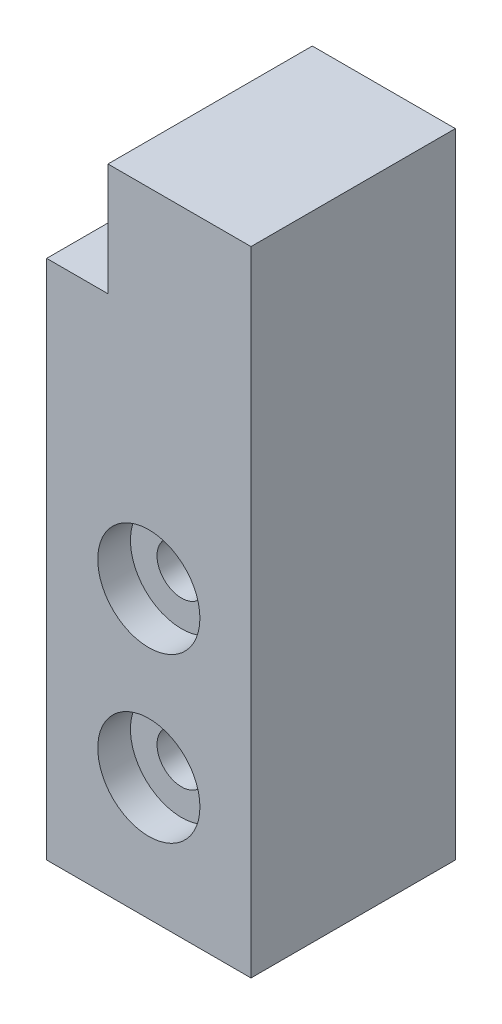
from build123d import *

# Parameters (mm, degrees)
SKETCH1_W                                = 10
SKETCH1_H                                = 31
BOSS_EXTRUDE1_DEPTH                      = 10
SKETCH2_W                                = 3
SKETCH2_H                                = 5.5
CUT_EXTRUDE1_DEPTH                       = 10
CBORE_FOR_M2_PAN_HEAD_SCREW1_D           = 2.4
CBORE_FOR_M2_PAN_HEAD_SCREW1_DEPTH       = 10
CBORE_FOR_M2_PAN_HEAD_SCREW1_CBORE_D     = 5
CBORE_FOR_M2_PAN_HEAD_SCREW1_CBORE_DEPTH = 1.6
CBORE_FOR_M2_PAN_HEAD_SCREW1_TIP         = 0.721032743


with BuildPart() as part:
    # Sketch1 → Boss-Extrude1 (new body)
    with BuildSketch(Plane.XY):
        with Locations((5, 15.5)):
            Rectangle(SKETCH1_W, SKETCH1_H)
    extrude(amount=BOSS_EXTRUDE1_DEPTH)

    # Sketch2 → Cut-Extrude1 (cut)
    with BuildSketch(Plane.XY.offset(10)):
        with Locations((1.5, 28.25)):
            Rectangle(SKETCH2_W, SKETCH2_H)
    extrude(amount=-CUT_EXTRUDE1_DEPTH, mode=Mode.SUBTRACT)

    # CBORE for M2 Pan Head Screw1
    with Locations(Plane.XY.offset(10)):
        with Locations((5, 14), (5, 6)):
            CounterBoreHole(CBORE_FOR_M2_PAN_HEAD_SCREW1_D / 2, CBORE_FOR_M2_PAN_HEAD_SCREW1_CBORE_D / 2, CBORE_FOR_M2_PAN_HEAD_SCREW1_CBORE_DEPTH, depth=CBORE_FOR_M2_PAN_HEAD_SCREW1_DEPTH)
            with Locations((0, 0, -(CBORE_FOR_M2_PAN_HEAD_SCREW1_DEPTH + CBORE_FOR_M2_PAN_HEAD_SCREW1_TIP / 2))):  # 118° drill point
                Cone(0, CBORE_FOR_M2_PAN_HEAD_SCREW1_D / 2, CBORE_FOR_M2_PAN_HEAD_SCREW1_TIP, mode=Mode.SUBTRACT)


solid = part.part
